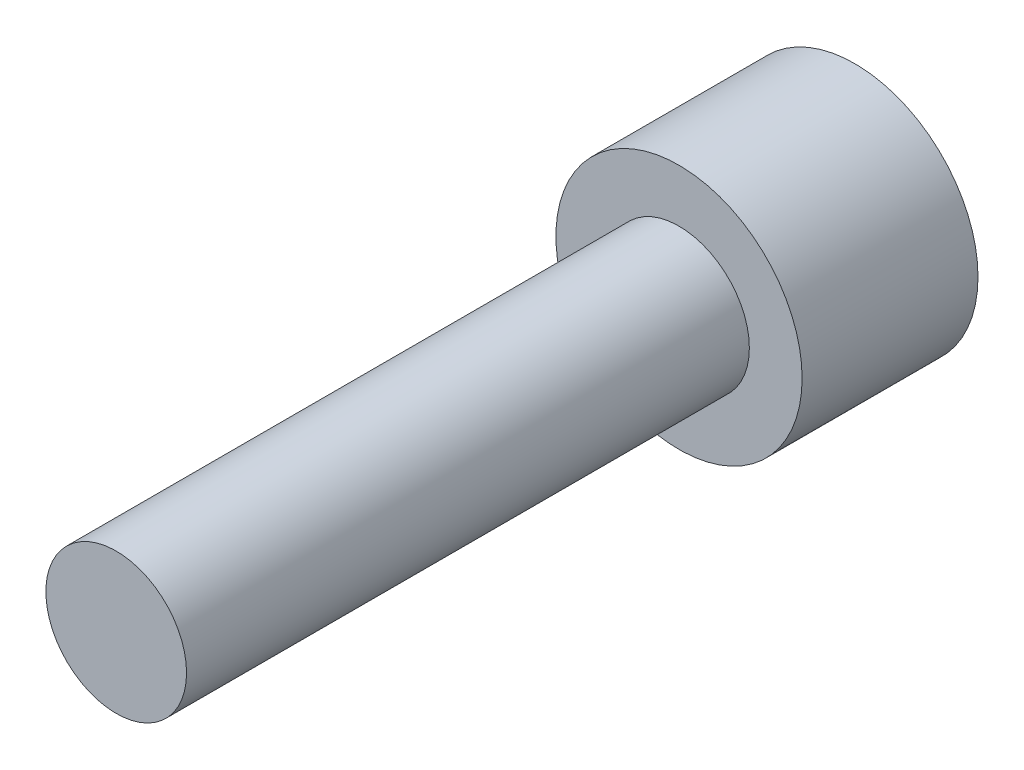
from build123d import *

# Parameters (mm, degrees)
CROQUIS1_R              = 1.75
SALIENTE_EXTRUIR1_DEPTH = 2.5
CROQUIS2_R              = 1
SALIENTE_EXTRUIR2_DEPTH = 8
CORTAR_EXTRUIR1_DEPTH   = 1.75


with BuildPart() as part:
    # Croquis1 → Saliente-Extruir1 (new body)
    with BuildSketch(Plane.XY):
        Circle(CROQUIS1_R)
    extrude(amount=SALIENTE_EXTRUIR1_DEPTH)

    # Croquis2 → Saliente-Extruir2 (add)
    with BuildSketch(Plane.XY.offset(2.5)):
        Circle(CROQUIS2_R)
    extrude(amount=SALIENTE_EXTRUIR2_DEPTH)

    # Croquis3 → Cortar-Extruir1 (cut)
    with BuildSketch(Plane(origin=(0, 0, 0), x_dir=(-1, 0, 0), z_dir=(0, 0, -1))):
        Polygon((1.443375673, 0), (0.721687836, 1.25), (-0.721687836, 1.25), (-1.443375673, 0), (-0.721687836, -1.25), (0.721687836, -1.25), align=None)
    extrude(amount=-CORTAR_EXTRUIR1_DEPTH, mode=Mode.SUBTRACT)


solid = part.part
